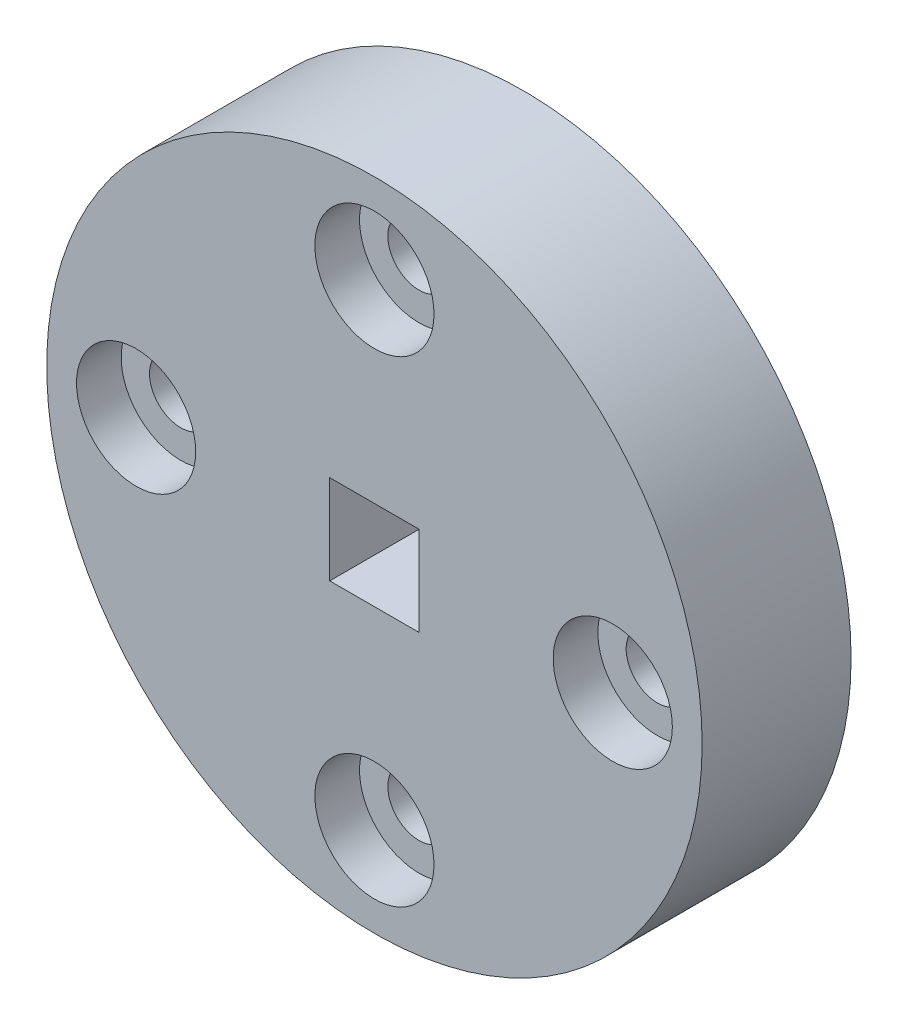
from build123d import *

# Parameters (mm, degrees)
BOSS_EXTRUDE1_DEPTH = 5
SKETCH5_R           = 2
CUT_EXTRUDE1_DEPTH  = 1.5
SKETCH2_W           = 3
SKETCH2_H           = 3
CUT_EXTRUDE2_DEPTH  = 10


with BuildPart() as part:
    # Sketch1 → Boss-Extrude1 (new body)
    with BuildSketch(Plane.XY):
        with BuildLine():
            ThreePointArc((-10.997222353, 0.247207602), (-0.699194891, -10.977755935), (10.939721705, -1.149999502))
            ThreePointArc((10.939721705, -1.149999502), (10.984920466, -0.575788859), (11.000000502, 4.98e-07))
            ThreePointArc((11.000000502, 4.98e-07), (10.991774906, 0.425318543), (10.967110422, 0.850000498))
            ThreePointArc((10.967110422, 0.850000498), (-0.301772264, 10.995860878), (-10.997222353, 0.247207602))
        make_face()
        with BuildLine():
            ThreePointArc((4.98e-07, -9.049999502), (1.050000497, -7.999999502), (4.96e-07, -6.949999502))
            ThreePointArc((4.96e-07, -6.949999502), (-1.049999502, -7.999999503), (4.98e-07, -9.049999502))
        make_face(mode=Mode.SUBTRACT)
        with BuildLine():
            ThreePointArc((8.000000496, 1.050000498), (6.950000497, 4.97e-07), (8.000000498, -1.049999502))
            ThreePointArc((8.000000498, -1.049999502), (9.050000498, 4.98e-07), (8.000000496, 1.050000498))
        make_face(mode=Mode.SUBTRACT)
        with BuildLine():
            ThreePointArc((4.96e-07, 9.050000498), (-1.049999503, 8.000000497), (4.98e-07, 6.950000498))
            ThreePointArc((4.98e-07, 6.950000498), (1.050000498, 8.000000498), (4.96e-07, 9.050000498))
        make_face(mode=Mode.SUBTRACT)
        with BuildLine():
            ThreePointArc((-9.049999498, -9.4808e-05), (-8.742427926, -0.742495317), (-7.999999502, -1.049999502))
            ThreePointArc((-7.999999502, -1.049999502), (-6.949999502, 4.95e-07), (-7.999999497, 1.050000498))
            ThreePointArc((-7.999999497, 1.050000498), (-8.742495315, 0.742428924), (-9.049999498, -9.4808e-05))
        make_face(mode=Mode.SUBTRACT)
    extrude(amount=BOSS_EXTRUDE1_DEPTH)

    # Sketch5 → Cut-Extrude1 (cut)
    with BuildSketch(Plane.XY.offset(5)):
        with Locations((8.000000497, 4.98e-07)):
            Circle(SKETCH5_R)
        with Locations((4.97e-07, -7.999999502)):
            Circle(SKETCH5_R)
        with Locations((-7.999999502, 4.98e-07)):
            Circle(SKETCH5_R)
        with Locations((4.97e-07, 8.000000498)):
            Circle(SKETCH5_R)
    extrude(amount=-CUT_EXTRUDE1_DEPTH, mode=Mode.SUBTRACT)

    # Sketch2 → Cut-Extrude2 (cut)
    with BuildSketch(Plane.XY.offset(5)):
        Rectangle(SKETCH2_W, SKETCH2_H)
    extrude(amount=-CUT_EXTRUDE2_DEPTH, mode=Mode.SUBTRACT)


solid = part.part
